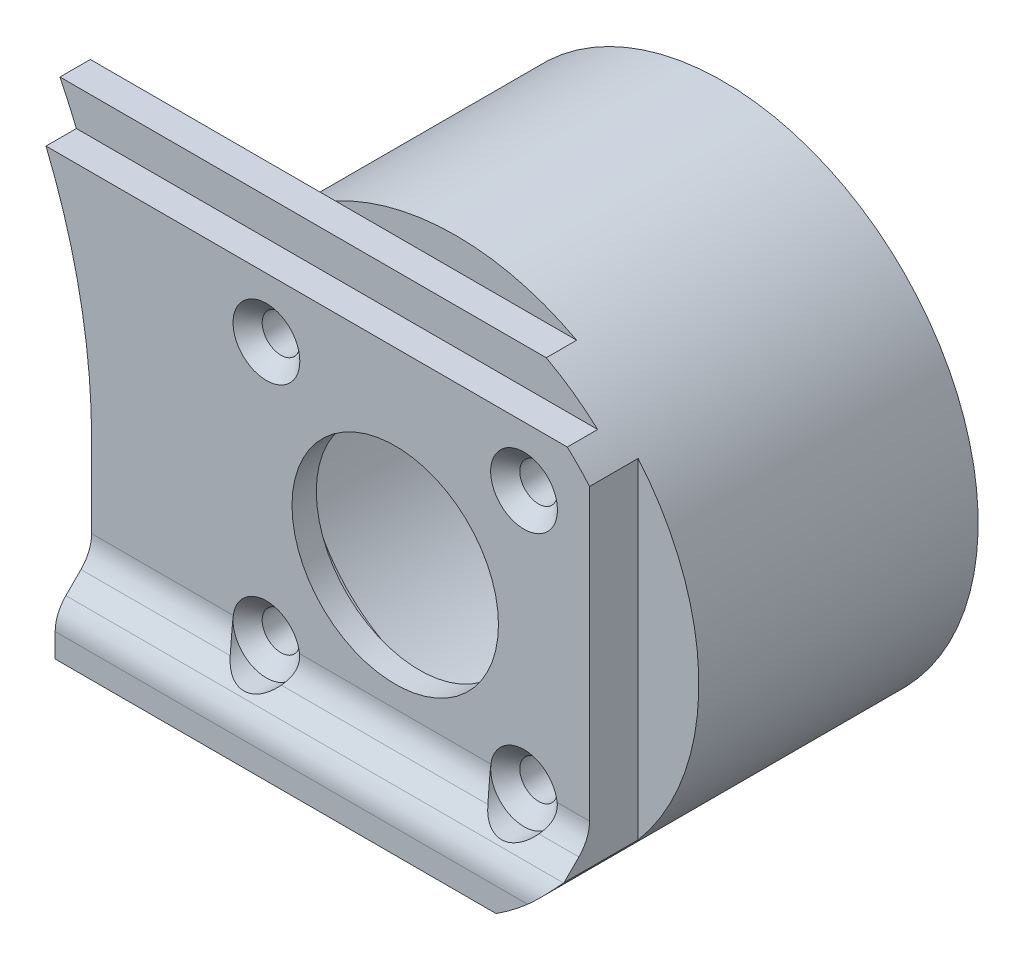
from build123d import *

# Parameters (mm, degrees)
SZKIC1_W                                   = 60
SZKIC1_H                                   = 31
SZKIC1_R                                   = 12.5
DODANIE_WYCI_GNI_CIE1_DEPTH                = 5
SZKIC11_R                                  = 12.5
SZKIC11_R_2                                = 8.5
DODANIE_WYCI_GNI_CIE5_DEPTH                = 2
SZKIC7_W                                   = 2.5
SZKIC7_H                                   = 3
DODANIE_WYCI_GNI_CIE3_DEPTH                = 60
ZAOKR_GLENIE1_R                            = 3
WYTNIJ_WYCI_GNI_CIE1_DEPTH                 = 4
WYTNIJ_WYCI_GNI_CIE1_DEPTH_BACK            = 6
SZKIC3_R                                   = 21
SZKIC3_R_2                                 = 18
DODANIE_WYCI_GNI_CIE2_DEPTH                = 22
POG_BIENIE_STO_KOWE_POD_M2_5_RUB_Z_2_COUNT = 2
POG_BIENIE_STO_KOWE_POD_M2_5_RUB_Z_2_PITCH = 21.213203436
POG_BIENIE_STO_KOWE_POD_M2_5_RUB_Z_3_COUNT = 2
POG_BIENIE_STO_KOWE_POD_M2_5_RUB_Z_3_PITCH = 30
POG_BIENIE_STO_KOWE_POD_M2_5_RUB_Z_4_COUNT = 2
POG_BIENIE_STO_KOWE_POD_M2_5_RUB_Z_4_PITCH = 21.213203436
WYTNIJ_WYCI_GNI_CIE3_DEPTH                 = 4
DODANIE_WYCI_GNI_CIE4_DEPTH                = 1
WYTNIJ_WYCI_GNI_CIE2_DEPTH                 = 9


with BuildPart() as part:
    # Szkic1 → Dodanie-wyci_gni_cie1 (new body)
    with BuildSketch(Plane.XY):
        with Locations((-14, 0)):
            Rectangle(SZKIC1_W, SZKIC1_H)
        Circle(SZKIC1_R, mode=Mode.SUBTRACT)
    extrude(amount=DODANIE_WYCI_GNI_CIE1_DEPTH)

    # Szkic11 → Dodanie-wyci_gni_cie5 (add)
    with BuildSketch(Plane.XY.offset(5)):
        Circle(SZKIC11_R)
        Circle(SZKIC11_R_2, mode=Mode.SUBTRACT)
    extrude(amount=-DODANIE_WYCI_GNI_CIE5_DEPTH)

    # Szkic7 → Dodanie-wyci_gni_cie3 (add, through all)
    with BuildSketch(Plane.ZY.offset(44)):
        with Locations((1.25, 17)):
            Rectangle(SZKIC7_W, SZKIC7_H)
        with Locations((1.25, -17)):
            Rectangle(SZKIC7_W, SZKIC7_H)
        Polygon((5, -11.5), (5, -17.703597862), (8, -17.703597862), (8, -14.5), align=None)
    extrude(amount=-DODANIE_WYCI_GNI_CIE3_DEPTH)

    # Zaokr_glenie1
    zaokr_glenie1_edges = [part.edges().sort_by_distance(p)[0] for p in [
        (-14, -14.5, 8),
        (-14, -11.5, 5),
    ]]
    fillet(zaokr_glenie1_edges, radius=ZAOKR_GLENIE1_R)

    # Szkic2 → Wytnij-wyci_gni_cie1 (cut, two sides)
    with BuildSketch(Plane.XY.offset(5)) as wytnij_wyci_gni_cie1_sk:
        with BuildLine():
            Line((-25, -3.514225997), (-25, -20.5))
            Line((-25, -20.5), (-44, -20.5))
            Line((-44, -20.5), (-44, 35.715864495))
            ThreePointArc((-44, 35.715864495), (-30, 18.280268721), (-25, -3.514225997))
        make_face()
    extrude(amount=WYTNIJ_WYCI_GNI_CIE1_DEPTH, mode=Mode.SUBTRACT)
    extrude(wytnij_wyci_gni_cie1_sk.sketch, amount=-WYTNIJ_WYCI_GNI_CIE1_DEPTH_BACK, mode=Mode.SUBTRACT)

    # Szkic3 → Dodanie-wyci_gni_cie2 (add)
    with BuildSketch(Plane(origin=(0, 0, 0), x_dir=(-1, 0, 0), z_dir=(0, 0, -1))):
        Circle(SZKIC3_R)
        Circle(SZKIC3_R_2, mode=Mode.SUBTRACT)
    extrude(amount=DODANIE_WYCI_GNI_CIE2_DEPTH)

    # Szkic6 → Pog_bienie sto_kowe pod M2.5 _rub_ z _be (revolve, cut)
    with BuildSketch(Plane(origin=(-10.606601718, 10.606601718, 5), x_dir=(0, -1, 0), z_dir=(1, 0, 0))):
        Polygon((0, 0), (0, 27), (1.55, 27), (1.55, 1.2), (2.75, 0), align=None)
    pog_bienie_sto_kowe_pod_m2_5_rub_z_be = revolve(axis=Axis((-10.606601718, 10.606601718, 11.35), (0, 0, -1)), mode=Mode.SUBTRACT)

    # Pog_bienie sto_kowe pod M2.5 _rub_ z 2: Pog_bienie sto_kowe pod M2.5 _rub_ z _be ×2
    with Locations(*[(0, -i * POG_BIENIE_STO_KOWE_POD_M2_5_RUB_Z_2_PITCH, 0) for i in range(1, POG_BIENIE_STO_KOWE_POD_M2_5_RUB_Z_2_COUNT)]):
        add(pog_bienie_sto_kowe_pod_m2_5_rub_z_be, mode=Mode.SUBTRACT)

    # Pog_bienie sto_kowe pod M2.5 _rub_ z 3: Pog_bienie sto_kowe pod M2.5 _rub_ z _be ×2
    with Locations(*[Vector(0.707106781, -0.707106781, 0) * (i * POG_BIENIE_STO_KOWE_POD_M2_5_RUB_Z_3_PITCH) for i in range(1, POG_BIENIE_STO_KOWE_POD_M2_5_RUB_Z_3_COUNT)]):
        add(pog_bienie_sto_kowe_pod_m2_5_rub_z_be, mode=Mode.SUBTRACT)

    # Pog_bienie sto_kowe pod M2.5 _rub_ z 4: Pog_bienie sto_kowe pod M2.5 _rub_ z _be ×2
    with Locations(*[(i * POG_BIENIE_STO_KOWE_POD_M2_5_RUB_Z_4_PITCH, 0, 0) for i in range(1, POG_BIENIE_STO_KOWE_POD_M2_5_RUB_Z_4_COUNT)]):
        add(pog_bienie_sto_kowe_pod_m2_5_rub_z_be, mode=Mode.SUBTRACT)

    # Szkic15 → Wytnij-wyci_gni_cie3 (cut, through all)
    with BuildSketch(Plane.XY.offset(5)):
        with BuildLine():
            ThreePointArc((-13.334335162, -10.257359313), (-10.606601718, -13.356601718), (-7.878868274, -10.257359313))
            ThreePointArc((-7.878868274, -10.257359313), (-10.606601718, -7.856601718), (-13.334335162, -10.257359313))
        make_face()
        with BuildLine():
            ThreePointArc((7.878868274, -10.257359313), (10.606601718, -13.356601718), (13.334335162, -10.257359313))
            ThreePointArc((13.334335162, -10.257359313), (10.606601718, -7.856601718), (7.878868274, -10.257359313))
        make_face()
    extrude(amount=WYTNIJ_WYCI_GNI_CIE3_DEPTH, mode=Mode.SUBTRACT)

    # Szkic8 → Dodanie-wyci_gni_cie4 (add)
    with BuildSketch(Plane.XY):
        with BuildLine():
            Line((16, 13.601470509), (16, -13.601470509))
            ThreePointArc((16, -13.601470509), (21, 0), (16, 13.601470509))
        make_face()
    extrude(amount=DODANIE_WYCI_GNI_CIE4_DEPTH)

    # Szkic8_3 → Wytnij-wyci_gni_cie2 (cut, through all)
    with BuildSketch(Plane.XY):
        with BuildLine():
            ThreePointArc((9.937303457, 18.5), (13.19790989, 16.334478092), (16, 13.601470509))
            Line((16, 13.601470509), (16, 18.5))
            Line((16, 18.5), (9.937303457, 18.5))
        make_face()
        with BuildLine():
            Line((16, -18.5), (16, -13.601470509))
            ThreePointArc((16, -13.601470509), (13.19790989, -16.334478092), (9.937303457, -18.5))
            Line((9.937303457, -18.5), (16, -18.5))
        make_face()
    extrude(amount=WYTNIJ_WYCI_GNI_CIE2_DEPTH, mode=Mode.SUBTRACT)


solid = part.part
